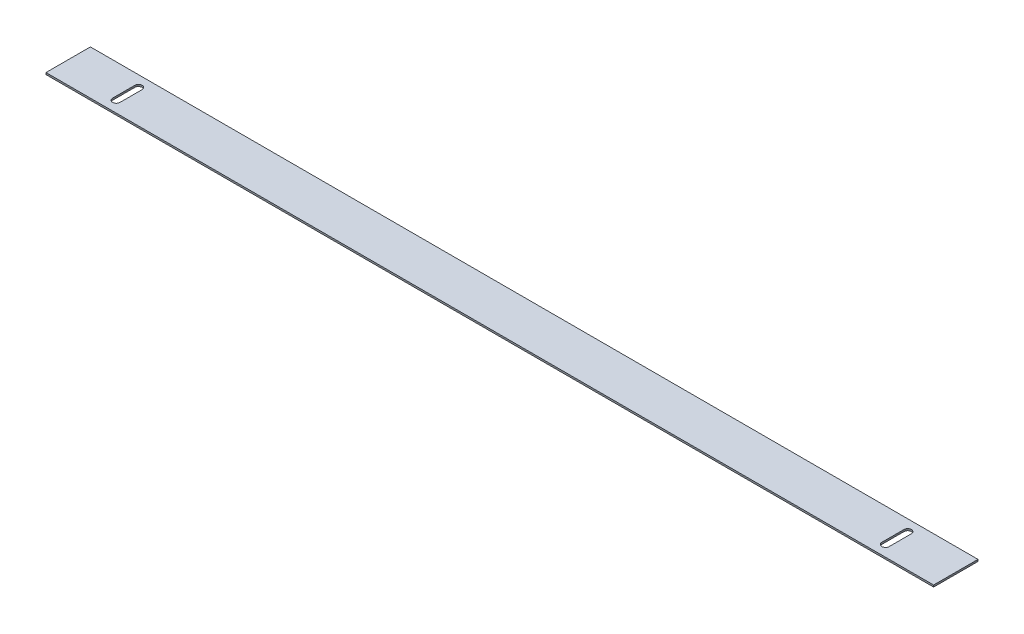
from build123d import *

# Parameters (mm, degrees)
SKETCH1_W           = 762
SKETCH1_H           = 38.1
BOSS_EXTRUDE1_DEPTH = 0.79375


with BuildPart() as part:
    # Sketch1 → Boss-Extrude1 (new body, symmetric)
    with BuildSketch(Plane(origin=(0, 0, 0), x_dir=(1, 0, 0), z_dir=(0, 1, 0))):
        Rectangle(SKETCH1_W, SKETCH1_H)
        with BuildLine():
            Line((-327.025, 9.525), (-327.025, -9.525))
            ThreePointArc((-327.025, -9.525), (-330.2, -12.7), (-333.375, -9.525))
            Line((-333.375, -9.525), (-333.375, 9.525))
            ThreePointArc((-333.375, 9.525), (-330.2, 12.7), (-327.025, 9.525))
        make_face(mode=Mode.SUBTRACT)
        with BuildLine():
            Line((327.025, 9.525), (327.025, -9.525))
            ThreePointArc((327.025, -9.525), (330.2, -12.7), (333.375, -9.525))
            Line((333.375, -9.525), (333.375, 9.525))
            ThreePointArc((333.375, 9.525), (330.2, 12.7), (327.025, 9.525))
        make_face(mode=Mode.SUBTRACT)
    extrude(amount=BOSS_EXTRUDE1_DEPTH, both=True)


with BuildPart() as body_2:
    # Split1: the piece on the far side of the plane
    add(part.part)
    split(bisect_by=Plane.ZX, keep=Keep.BOTTOM)


with BuildPart() as part_1:
    add(part.part)

    # Split1
    split(bisect_by=Plane.ZX, keep=Keep.TOP)


solid = Compound([body_2.part, part_1.part])
